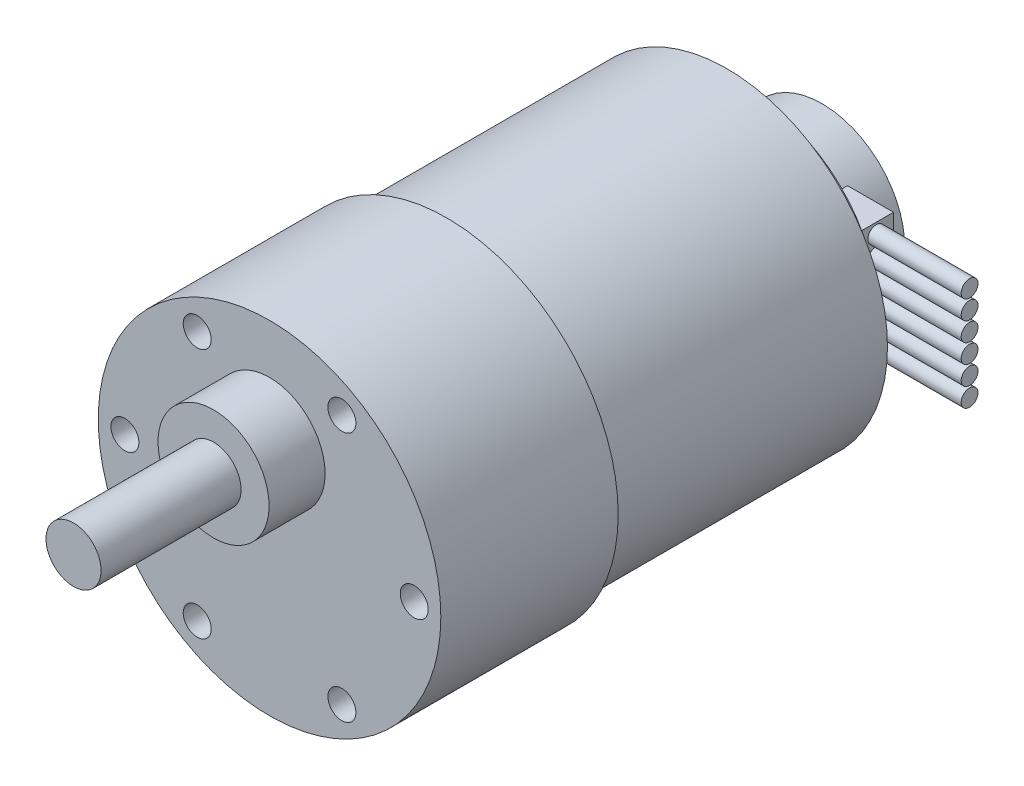
from build123d import *

# Parameters (mm, degrees)
SKETCH1_R           = 18.35
BOSS_EXTRUDE1_DEPTH = 19
SKETCH1_3_R         = 17.2
BOSS_EXTRUDE2_DEPTH = 30
SKETCH2_R           = 1.5
CUT_EXTRUDE1_DEPTH  = 5
SKETCH2_3_R         = 5.95
BOSS_EXTRUDE3_DEPTH = 6
SKETCH2_4_R         = 2.95
BOSS_EXTRUDE4_DEPTH = 21
SKETCH3_R           = 13.25
BOSS_EXTRUDE5_DEPTH = 2.9
SKETCH4_R           = 8.85
BOSS_EXTRUDE6_DEPTH = 10.2
SKETCH5_W           = 5.5
SKETCH5_H           = 12.4
BOSS_EXTRUDE7_DEPTH = 6.6
SKETCH6_R           = 0.9
BOSS_EXTRUDE8_DEPTH = 10


with BuildPart() as part:
    # Sketch1 → Boss-Extrude1 (new body)
    with BuildSketch(Plane.XY):
        Circle(SKETCH1_R)
    extrude(amount=BOSS_EXTRUDE1_DEPTH)

    # Sketch1_3 → Boss-Extrude2 (add)
    with BuildSketch(Plane.XY):
        Circle(SKETCH1_3_R)
    extrude(amount=-BOSS_EXTRUDE2_DEPTH)

    # Sketch2 → Cut-Extrude1 (cut)
    with BuildSketch(Plane.XY.offset(19)):
        with Locations((15.5, 0)):
            Circle(SKETCH2_R)
        with Locations((7.75, -13.423393759)):
            Circle(SKETCH2_R)
        with Locations((-7.75, -13.423393759)):
            Circle(SKETCH2_R)
        with Locations((-15.5, 0)):
            Circle(SKETCH2_R)
        with Locations((-7.75, 13.423393759)):
            Circle(SKETCH2_R)
        with Locations((7.75, 13.423393759)):
            Circle(SKETCH2_R)
    extrude(amount=-CUT_EXTRUDE1_DEPTH, mode=Mode.SUBTRACT)

    # Sketch2_3 → Boss-Extrude3 (add)
    with BuildSketch(Plane.XY.offset(19)):
        with Locations((0, 7.1)):
            Circle(SKETCH2_3_R)
    extrude(amount=BOSS_EXTRUDE3_DEPTH)

    # Sketch2_4 → Boss-Extrude4 (add)
    with BuildSketch(Plane.XY.offset(19)):
        with Locations((0, 7.1)):
            Circle(SKETCH2_4_R)
    extrude(amount=BOSS_EXTRUDE4_DEPTH)

    # Sketch3 → Boss-Extrude5 (add)
    with BuildSketch(Plane(origin=(0, 0, -30), x_dir=(-1, 0, 0), z_dir=(0, 0, -1))):
        Circle(SKETCH3_R)
    extrude(amount=BOSS_EXTRUDE5_DEPTH)

    # Sketch4 → Boss-Extrude6 (add)
    with BuildSketch(Plane(origin=(0, 0, -30), x_dir=(-1, 0, 0), z_dir=(0, 0, -1))):
        Circle(SKETCH4_R)
    extrude(amount=BOSS_EXTRUDE6_DEPTH)

    # Sketch5 → Boss-Extrude7 (add)
    with BuildSketch(Plane(origin=(0, 0, -30), x_dir=(-1, 0, 0), z_dir=(0, 0, -1))):
        with Locations((-8.5, 0)):
            Rectangle(SKETCH5_W, SKETCH5_H)
    extrude(amount=BOSS_EXTRUDE7_DEPTH)

    # Sketch6 → Boss-Extrude8 (add)
    with BuildSketch(Plane(origin=(11.25, 0, 0), x_dir=(0, 0, -1), z_dir=(1, 0, 0))):
        with Locations((34.75, 5.071428571)):
            Circle(SKETCH6_R)
        with Locations((34.75, -5.071428571)):
            Circle(SKETCH6_R)
        with Locations((34.75, -3.042857143)):
            Circle(SKETCH6_R)
        with Locations((34.75, -1.014285714)):
            Circle(SKETCH6_R)
        with Locations((34.75, 1.014285714)):
            Circle(SKETCH6_R)
        with Locations((34.75, 3.042857143)):
            Circle(SKETCH6_R)
    extrude(amount=BOSS_EXTRUDE8_DEPTH)


solid = part.part
